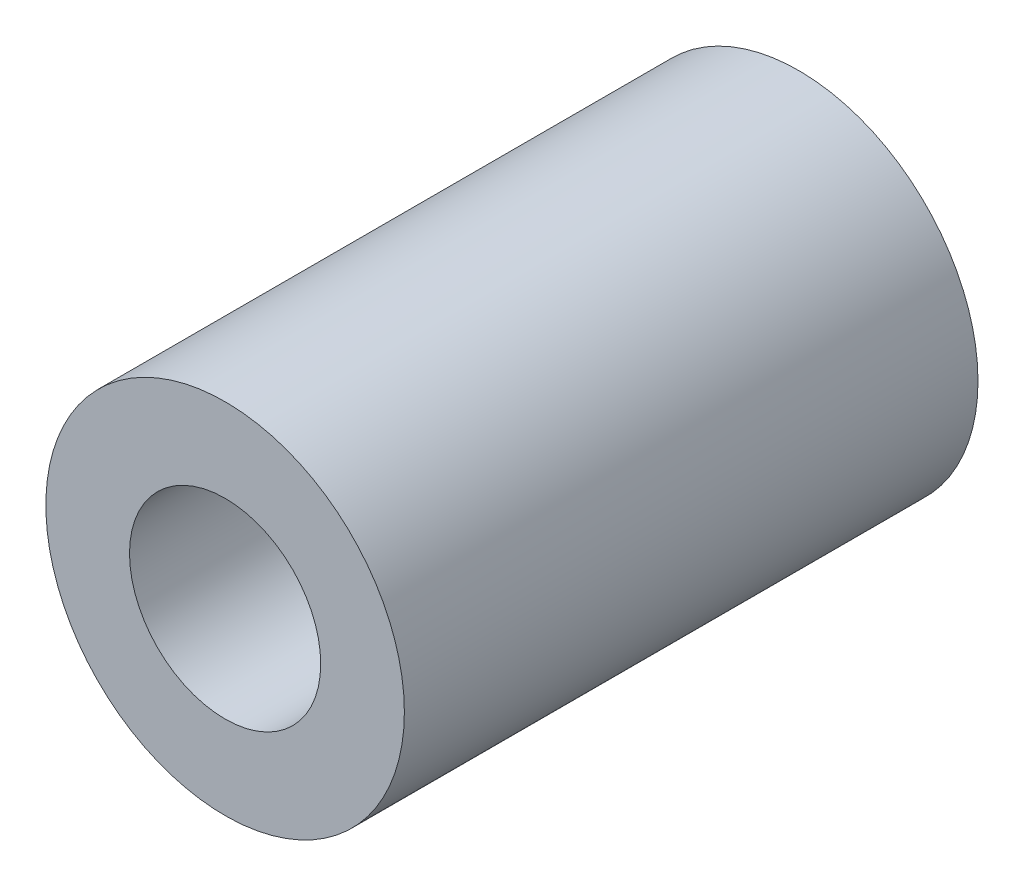
from build123d import *

# Parameters (mm, degrees)
ESQUISSE1_R        = 7.5
ESQUISSE1_R_2      = 4
BOSS_EXTRU_1_DEPTH = 24


with BuildPart() as part:
    # Esquisse1 → Boss.-Extru.1 (new body)
    with BuildSketch(Plane.XY):
        Circle(ESQUISSE1_R)
        Circle(ESQUISSE1_R_2, mode=Mode.SUBTRACT)
    extrude(amount=BOSS_EXTRU_1_DEPTH)


solid = part.part
